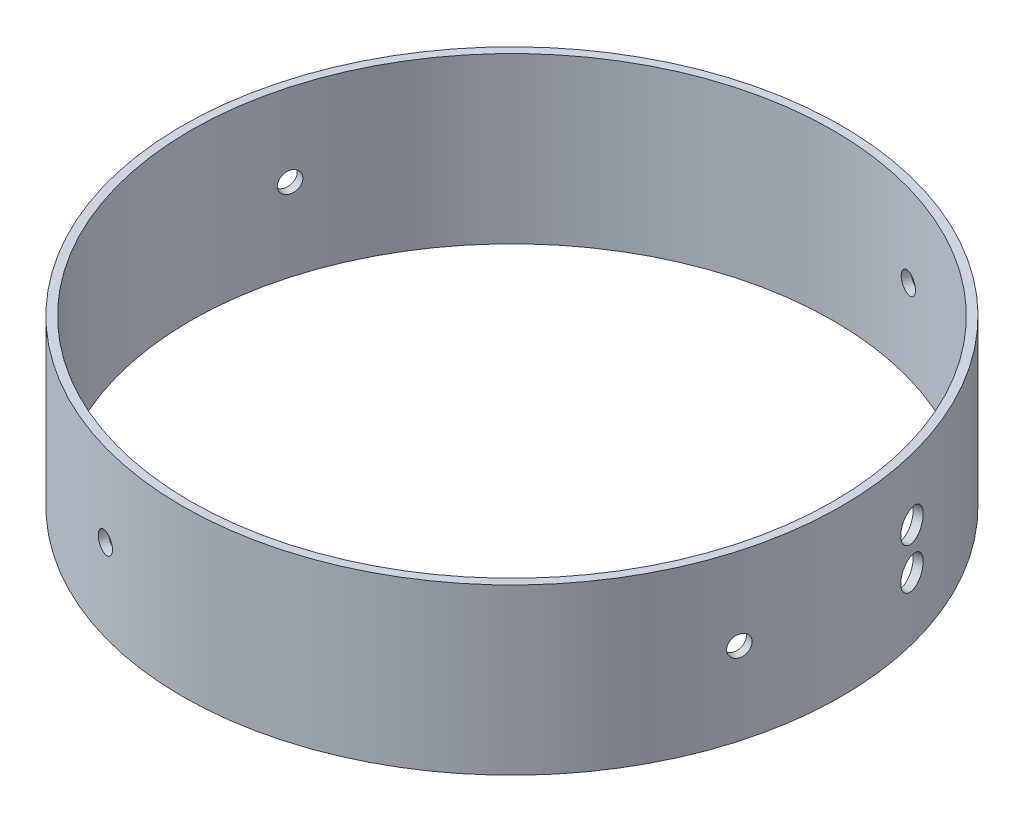
from build123d import *

# Parameters (mm, degrees)
SKETCH1_R           = 50.8
SKETCH1_R_2         = 49.53
BOSS_EXTRUDE1_DEPTH = 25.4
SKETCH2_R           = 2.38125
CUT_EXTRUDE1_DEPTH  = 25.4
SKETCH3_R           = 1.5875
CUT_EXTRUDE2_DEPTH  = 37.338
CIRPATTERN1_COUNT   = 4


with BuildPart() as part:
    # Sketch1 → Boss-Extrude1 (new body)
    with BuildSketch(Plane(origin=(0, 0, 0), x_dir=(1, 0, 0), z_dir=(0, 1, 0))):
        Circle(SKETCH1_R)
        Circle(SKETCH1_R_2, mode=Mode.SUBTRACT)
    extrude(amount=BOSS_EXTRUDE1_DEPTH)

    # Sketch2 → Cut-Extrude1 (cut)
    with BuildSketch(Plane(origin=(80.709285485, 206.333156205, 111.645979585), x_dir=(0, -1, 0), z_dir=(0.969338628, 0, -0.24572876))):
        with Locations((196.808156205, 128.055353348)):
            Circle(SKETCH2_R)
        with Locations((190.458156205, 128.055353348)):
            Circle(SKETCH2_R)
    extrude(amount=-CUT_EXTRUDE1_DEPTH, mode=Mode.SUBTRACT)

    # Sketch3 → Cut-Extrude2 (cut)
    with BuildSketch(Plane(origin=(-3.10026152, 207.778194099, 134.798971935), x_dir=(0, 1, 0), z_dir=(-0.962336257, 0, -0.271861966))):
        with Locations((-195.078194099, 130.56478129)):
            Circle(SKETCH3_R)
    cut_extrude2 = extrude(amount=-CUT_EXTRUDE2_DEPTH, mode=Mode.SUBTRACT)

    # CirPattern1: Cut-Extrude2 ×4 about axis
    cirpattern1_axis = Axis((0, 0, 0), (0, -1, 0))
    for i in range(1, CIRPATTERN1_COUNT):
        add(cut_extrude2.rotate(cirpattern1_axis, i * 360 / CIRPATTERN1_COUNT), mode=Mode.SUBTRACT)


solid = part.part
